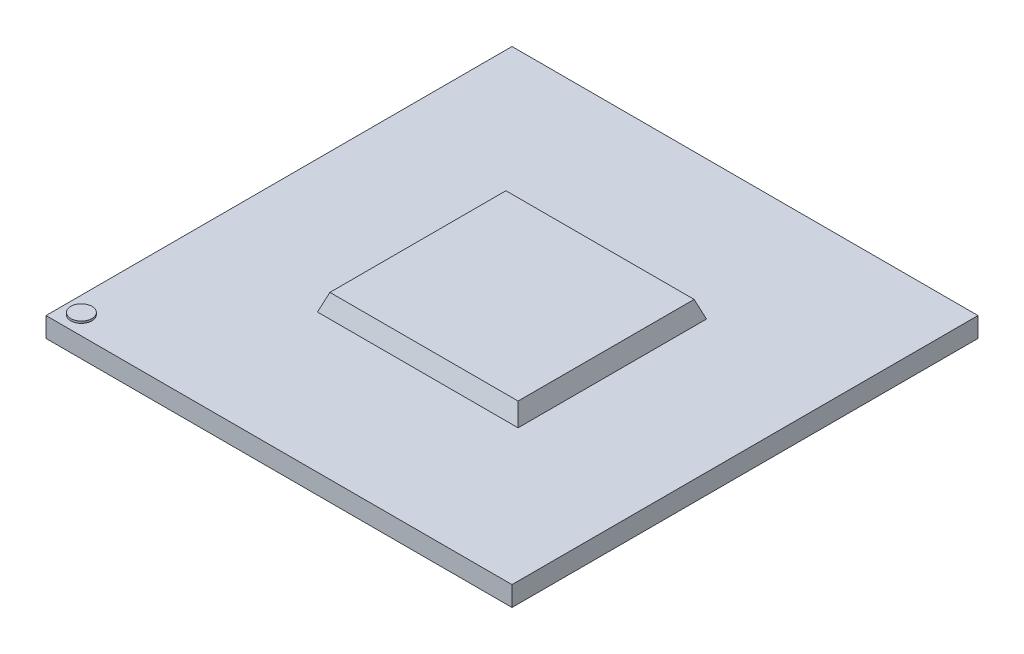
from build123d import *

# Parameters (mm, degrees)
SKETCH8_W            = 23
SKETCH8_H            = 23
BOSS_EXTRUDE4_DEPTH  = 0.98
SKETCH16_W           = 9.9
SKETCH16_H           = 9.3
BOSS_EXTRUDE11_DEPTH = 0.84
BOSS_EXTRUDE11_TAPER = 20
SKETCH17_R           = 0.522081484
BOSS_EXTRUDE12_DEPTH = 0.1


with BuildPart() as part:
    # Sketch8 → Boss-Extrude4 (new body)
    with BuildSketch(Plane(origin=(0, 0, 0), x_dir=(1, 0, 0), z_dir=(0, 1, 0))):
        Rectangle(SKETCH8_W, SKETCH8_H)
    extrude(amount=BOSS_EXTRUDE4_DEPTH)

    # Sketch16 → Boss-Extrude11 (add)
    with BuildSketch(Plane(origin=(0, 0.98, 0), x_dir=(1, 0, 0), z_dir=(0, 1, 0))):
        Rectangle(SKETCH16_W, SKETCH16_H)
    extrude(amount=BOSS_EXTRUDE11_DEPTH, taper=BOSS_EXTRUDE11_TAPER)

    # Sketch17 → Boss-Extrude12 (add)
    with BuildSketch(Plane(origin=(0, 0.98, 0), x_dir=(1, 0, 0), z_dir=(0, 1, 0))):
        with Locations((-10.659163623, -10.593903438)):
            Circle(SKETCH17_R)
    extrude(amount=BOSS_EXTRUDE12_DEPTH)


solid = part.part
